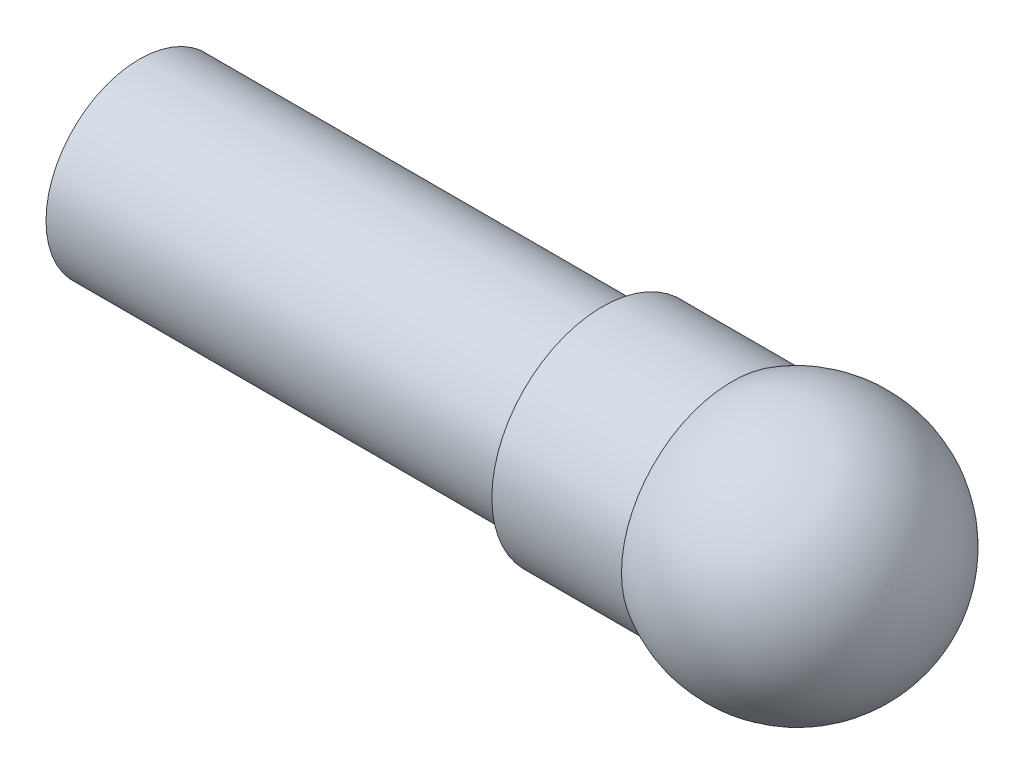
from build123d import *


with BuildPart() as part:
    # Sketch1 → Revolve3 (revolve)
    with BuildSketch(Plane(origin=(0, 0, 0), x_dir=(1, 0, 0), z_dir=(0, 1, 0))):
        Polygon((-64, -22.159983722), (-64, -20.159983722), (-14, -20.159983722), (0, -20.159983722), (0, -22.159983722), (-14, -22.159983722), align=None)
        with BuildLine():
            Line((20.916121764, -12.079991861), (18.884815844, -12.079991861))
            ThreePointArc((18.884815844, -12.079991861), (12.465262752, -22.783291649), (0, -22.159983722))
            Line((0, -22.159983722), (-14, -22.159983722))
            Line((-14, -22.159983722), (-14, -24))
            Line((-14, -24), (0, -24))
            ThreePointArc((0, -24), (13.89849199, -24.076944491), (20.916121764, -12.079991861))
        make_face()
    revolve(axis=Axis((-74.418855498, 0, 12.079991861), (1, 0, 0)))


solid = part.part
